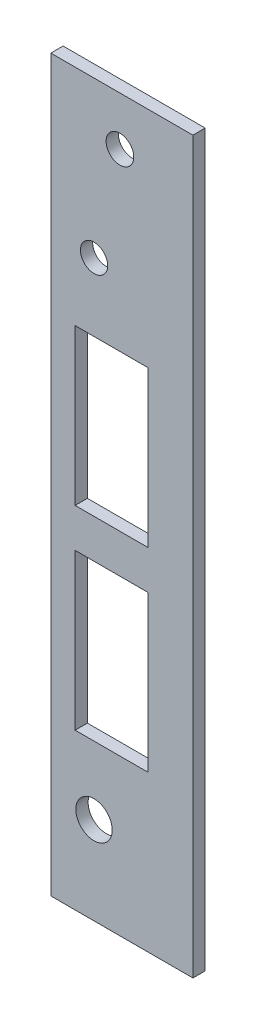
from build123d import *

# Parameters (mm, degrees)
SKETCH1_W          = 18.542
SKETCH1_H          = 95.25
EXTRUDE1_DEPTH     = 1.6002
SKETCH2_R          = 1.8034
CUT_EXTRUDE1_DEPTH = 1.6002
SKETCH3_R          = 1.778
SKETCH3_R_2        = 2.3749
CUT_EXTRUDE2_DEPTH = 2.54
SKETCH4_W          = 9.525
SKETCH4_H          = 20.32
FIBER_HOLES_DEPTH  = 2.54


with BuildPart() as part:
    # Sketch1 → Extrude1 (new body)
    with BuildSketch(Plane.XY):
        with Locations((9.271, -47.625)):
            Rectangle(SKETCH1_W, SKETCH1_H)
    extrude(amount=EXTRUDE1_DEPTH)

    # Sketch2 → Cut-Extrude1 (cut)
    with BuildSketch(Plane.XY.offset(1.6002)):
        with Locations((9.017, -6.35)):
            Circle(SKETCH2_R)
    extrude(amount=-CUT_EXTRUDE1_DEPTH, mode=Mode.SUBTRACT)

    # Sketch3 → Cut-Extrude2 (cut)
    with BuildSketch(Plane.XY.offset(1.6002)):
        with Locations((5.6388, -20.32)):
            Circle(SKETCH3_R)
        with Locations((5.6388, -83.82)):
            Circle(SKETCH3_R_2)
    extrude(amount=-CUT_EXTRUDE2_DEPTH, mode=Mode.SUBTRACT)

    # Sketch4 → Fiber Holes (cut)
    with BuildSketch(Plane.XY.offset(1.6002)):
        with Locations((7.9375, -39.37)):
            Rectangle(SKETCH4_W, SKETCH4_H)
        with Locations((7.9375, -64.77)):
            Rectangle(SKETCH4_W, SKETCH4_H)
    extrude(amount=-FIBER_HOLES_DEPTH, mode=Mode.SUBTRACT)


solid = part.part
